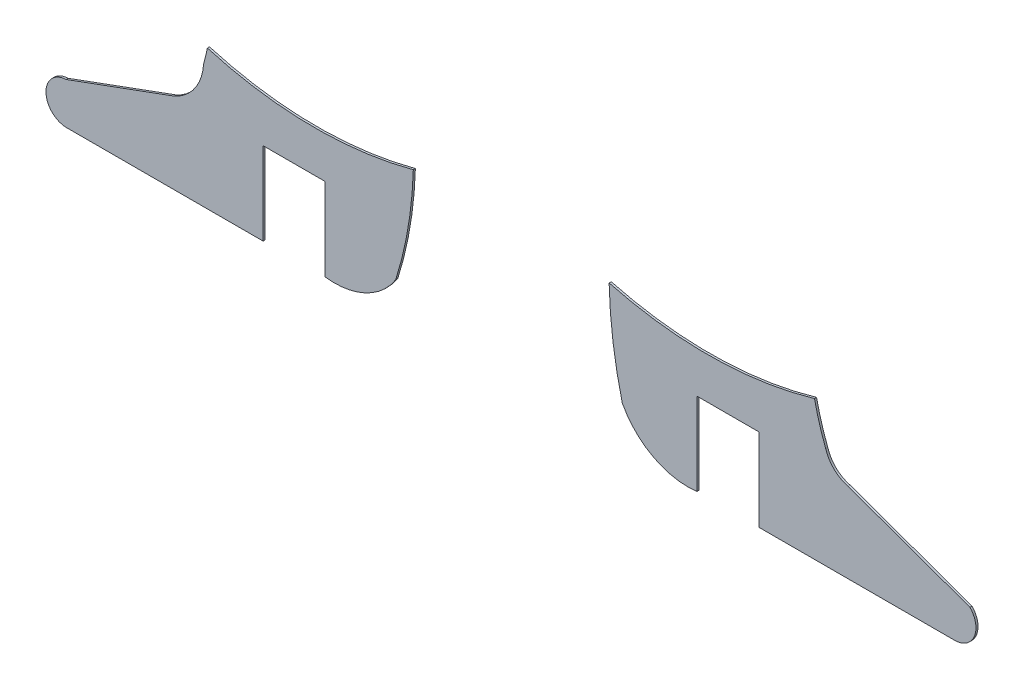
from build123d import *

# Parameters (mm, degrees)
SALIENTE_EXTRUIR1_DEPTH   = 0.1
SALIENTE_EXTRUIR1_2_DEPTH = 0.1


with BuildPart() as part:
    # Model → Saliente-Extruir1 (new body)
    with BuildSketch(Plane.XY):
        with BuildLine():
            Line((48.004911327, 11.481121887), (48.000129117, 15.480179105))
            Line((48.000129117, 15.480179105), (45.004326118, 15.479740685))
            Line((45.004326118, 15.479740685), (45.004911497, 11.479740728))
            Line((45.004911497, 11.479740728), (35.506169055, 11.478350639))
            ThreePointArc((35.506169055, 11.478350639), (34.492366192, 12.460645884), (35.46295571, 13.485661095))
            Line((35.46295571, 13.485661095), (40.665125807, 15.394449439))
            ThreePointArc((40.665125807, 15.394449439), (41.687092497, 16.219441411), (42.120437187, 17.459296261))
            ThreePointArc((42.120437187, 17.459296261), (42.218278721, 17.841092612), (42.304716772, 18.225631144))
            ThreePointArc((42.304716772, 18.225631144), (47.280668403, 17.482783386), (52.272757778, 18.108052207))
            ThreePointArc((52.272757778, 18.108052207), (52.021066511, 15.55801224), (51.419828955, 13.067115668))
            ThreePointArc((51.419828955, 13.067115668), (49.943203878, 11.777094004), (48.004911327, 11.481121887))
        make_face()
    extrude(amount=SALIENTE_EXTRUIR1_DEPTH)


with BuildPart() as body_2:
    # Model → Saliente-Extruir1 2 (new body)
    with BuildSketch(Plane.XY):
        with BuildLine():
            Line((73.321058857, 15.357458735), (79.220381344, 13.23671285))
            ThreePointArc((79.220381344, 13.23671285), (79.437035814, 12.14193667), (78.537134291, 11.481897812))
            Line((78.537134291, 11.481897812), (69.000129117, 11.481496513))
            Line((69.000129117, 11.481496513), (69.000129117, 15.481496513))
            Line((69.000129117, 15.481496513), (66.000129117, 15.481496513))
            Line((66.000129117, 15.481496513), (66.000129117, 11.481496513))
            ThreePointArc((66.000129117, 11.481496513), (63.899495069, 11.869675073), (62.389176946, 13.380398463))
            ThreePointArc((62.389176946, 13.380398463), (61.938549185, 15.723282994), (61.751187513, 18.101742351))
            ThreePointArc((61.751187513, 18.101742351), (66.729705671, 17.482905475), (71.691433552, 18.224429965))
            ThreePointArc((71.691433552, 18.224429965), (71.92782379, 17.300929573), (72.234139379, 16.398209196))
            ThreePointArc((72.234139379, 16.398209196), (72.641217064, 15.735401829), (73.321058857, 15.357458735))
        make_face()
    extrude(amount=SALIENTE_EXTRUIR1_2_DEPTH)


solid = Compound([part.part, body_2.part])
